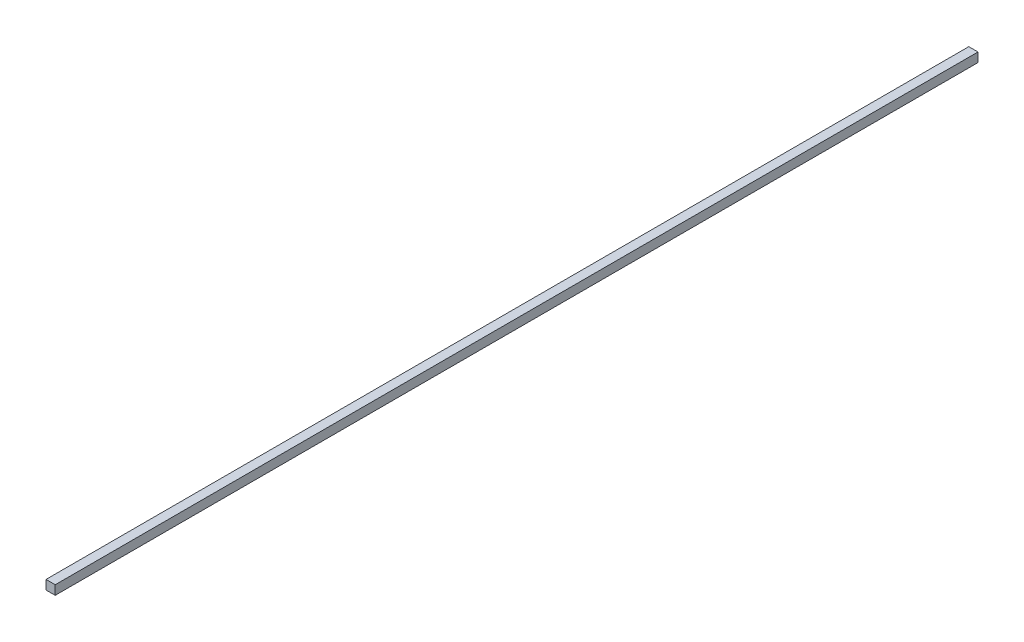
from build123d import *

# Parameters (mm, degrees)
SKETCH1_W           = 7.6
SKETCH1_H           = 7.6
BOSS_EXTRUDE1_DEPTH = 762


with BuildPart() as part:
    # Sketch1 → Boss-Extrude1 (new body)
    with BuildSketch(Plane.XY):
        Rectangle(SKETCH1_W, SKETCH1_H)
    extrude(amount=BOSS_EXTRUDE1_DEPTH)


solid = part.part
